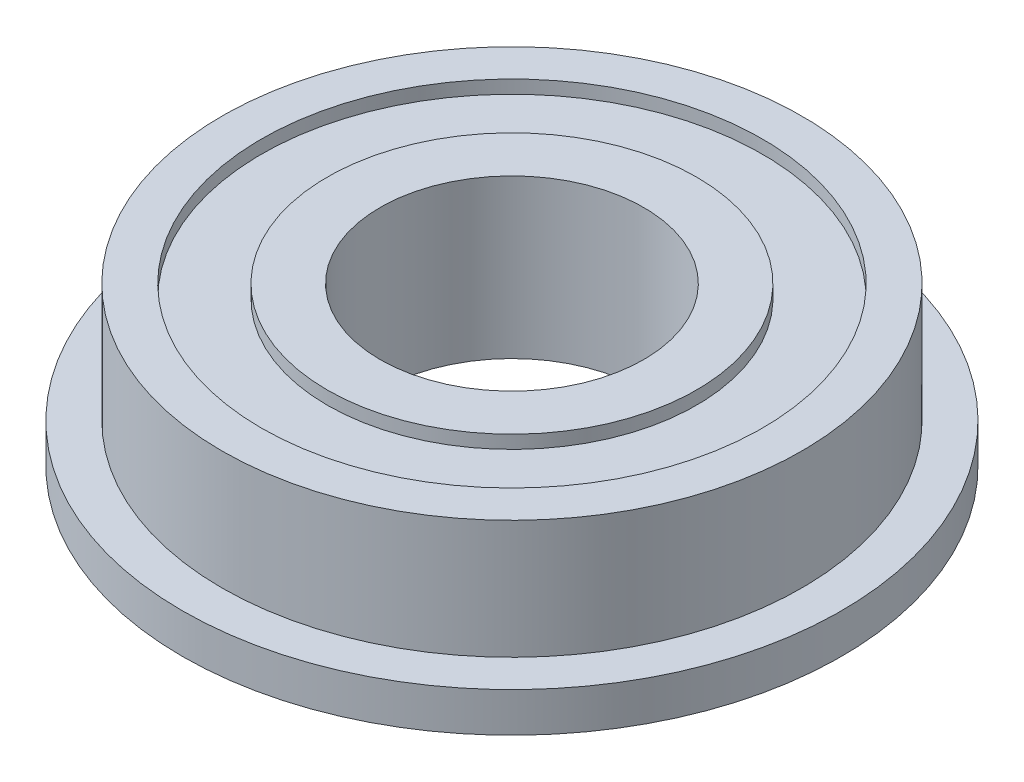
from build123d import *

# Parameters (mm, degrees)
SKETCH_1_R          = 12.5
EXTRUDE_1_DEPTH     = 1.5
SKETCH_2_R          = 11
EXTRUDE_2_DEPTH     = 4.5
SKETCH_3_R          = 5
CUT_EXTRUDE_1_DEPTH = 9
SKETCH_4_R          = 9.5
SKETCH_4_R_2        = 7
CUT_EXTRUDE_2_DEPTH = 0.5
SKETCH_5_R          = 9.5
SKETCH_5_R_2        = 7
CUT_EXTRUDE_3_DEPTH = 0.5


with BuildPart() as part:
    # 草图1 → 凸台-拉伸1 (new body)
    with BuildSketch(Plane(origin=(0, 0, 0), x_dir=(1, 0, 0), z_dir=(0, 1, 0))):
        Circle(SKETCH_1_R)
    extrude(amount=EXTRUDE_1_DEPTH)

    # 草图2 → 凸台-拉伸2 (add)
    with BuildSketch(Plane(origin=(0, 1.5, 0), x_dir=(1, 0, 0), z_dir=(0, 1, 0))):
        Circle(SKETCH_2_R)
    extrude(amount=EXTRUDE_2_DEPTH)

    # 草图3 → 切除-拉伸1 (cut)
    with BuildSketch(Plane(origin=(0, 6, 0), x_dir=(1, 0, 0), z_dir=(0, 1, 0))):
        Circle(SKETCH_3_R)
    extrude(amount=-CUT_EXTRUDE_1_DEPTH, mode=Mode.SUBTRACT)

    # 草图4 → 切除-拉伸2 (cut)
    with BuildSketch(Plane.XZ):
        Circle(SKETCH_4_R)
        Circle(SKETCH_4_R_2, mode=Mode.SUBTRACT)
    extrude(amount=-CUT_EXTRUDE_2_DEPTH, mode=Mode.SUBTRACT)

    # 草图5 → 切除-拉伸3 (cut)
    with BuildSketch(Plane(origin=(0, 6, 0), x_dir=(1, 0, 0), z_dir=(0, 1, 0))):
        Circle(SKETCH_5_R)
        Circle(SKETCH_5_R_2, mode=Mode.SUBTRACT)
    extrude(amount=-CUT_EXTRUDE_3_DEPTH, mode=Mode.SUBTRACT)


solid = part.part
